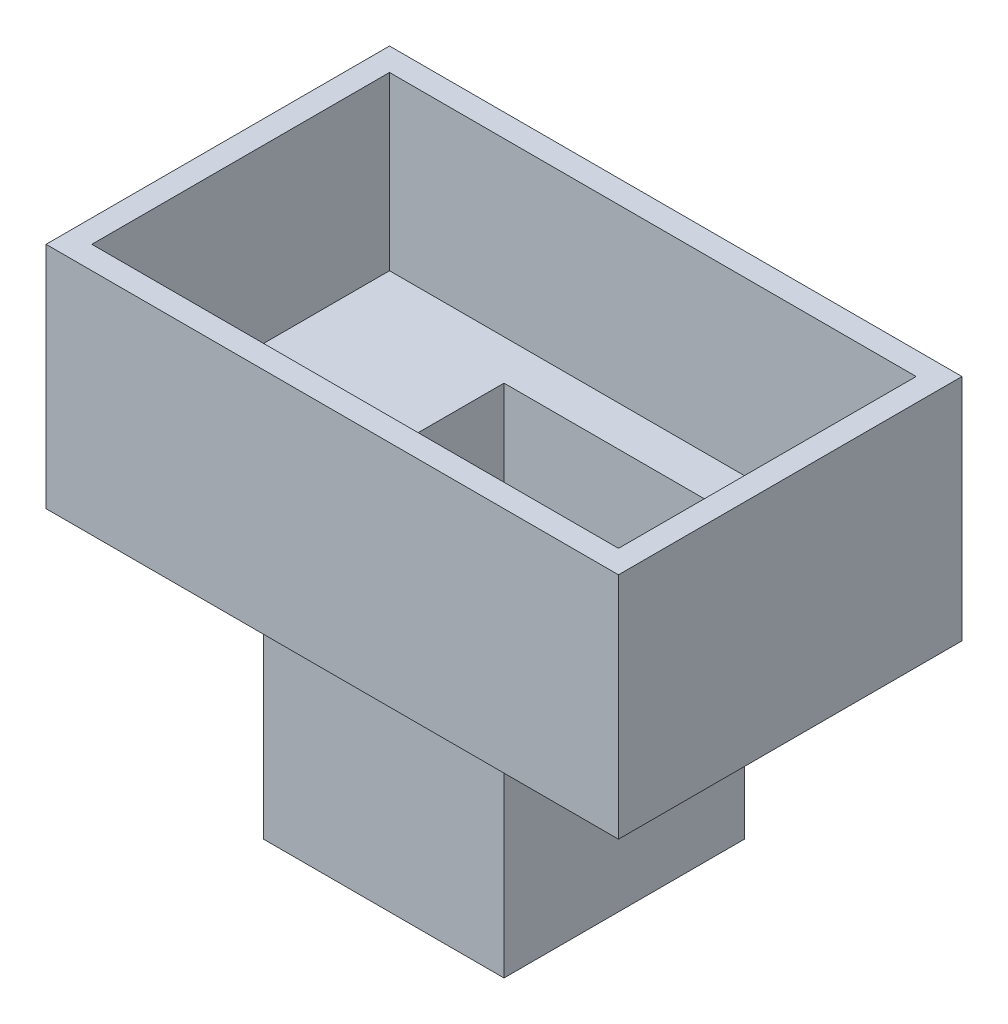
from build123d import *

# Parameters (mm, degrees)
SKETCH2_W           = 21
SKETCH2_H           = 21
BOSS_EXTRUDE1_DEPTH = 20
SKETCH3_W           = 19
SKETCH3_H           = 19
CUT_EXTRUDE1_DEPTH  = 21
SKETCH4_W           = 50
SKETCH4_H           = 30
BOSS_EXTRUDE2_DEPTH = 20
SKETCH5_W           = 46
SKETCH5_H           = 26
CUT_EXTRUDE2_DEPTH  = 15
SKETCH6_W           = 19
SKETCH6_H           = 19
CUT_EXTRUDE3_DEPTH  = 15


with BuildPart() as part:
    # Sketch2 → Boss-Extrude1 (new body)
    with BuildSketch(Plane(origin=(0, 0, 0), x_dir=(1, 0, 0), z_dir=(0, 1, 0))):
        with Locations((0.794117647, -2.823529412)):
            Rectangle(SKETCH2_W, SKETCH2_H)
    extrude(amount=BOSS_EXTRUDE1_DEPTH)

    # Sketch3 → Cut-Extrude1 (cut, through all)
    with BuildSketch(Plane(origin=(0, 20, 0), x_dir=(1, 0, 0), z_dir=(0, 1, 0))):
        with Locations((0.794117647, -2.823529412)):
            Rectangle(SKETCH3_W, SKETCH3_H)
    extrude(amount=-CUT_EXTRUDE1_DEPTH, mode=Mode.SUBTRACT)

    # Sketch4 → Boss-Extrude2 (add)
    with BuildSketch(Plane(origin=(0, 20, 0), x_dir=(1, 0, 0), z_dir=(0, 1, 0))):
        with Locations((0.794117647, -2.823529412)):
            Rectangle(SKETCH4_W, SKETCH4_H)
    extrude(amount=BOSS_EXTRUDE2_DEPTH)

    # Sketch5 → Cut-Extrude2 (cut)
    with BuildSketch(Plane(origin=(0, 40, 0), x_dir=(1, 0, 0), z_dir=(0, 1, 0))):
        with Locations((0.794117647, -2.823529412)):
            Rectangle(SKETCH5_W, SKETCH5_H)
    extrude(amount=-CUT_EXTRUDE2_DEPTH, mode=Mode.SUBTRACT)

    # Sketch6 → Cut-Extrude3 (cut)
    with BuildSketch(Plane.XZ.offset(-20)):
        with Locations((0.794117647, 2.823529412)):
            Rectangle(SKETCH6_W, SKETCH6_H)
    extrude(amount=-CUT_EXTRUDE3_DEPTH, mode=Mode.SUBTRACT)


solid = part.part
